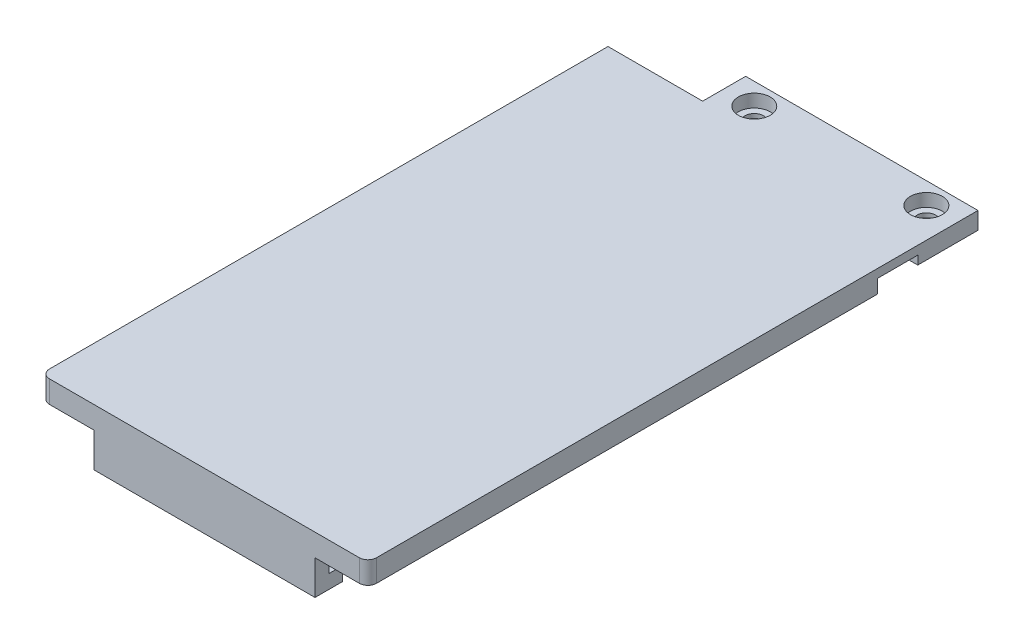
from build123d import *

# Parameters (mm, degrees)
SKETCH1_W                = 38
SKETCH1_H                = 65.9
BOSS_EXTRUDE1_DEPTH      = 1
BOSS_EXTRUDE2_DEPTH      = 1.58
SKETCH3_W                = 25.7
SKETCH3_H                = 1.6
BOSS_EXTRUDE3_DEPTH      = 4
SKETCH4_W                = 25.7
SKETCH4_H                = 1.6
BOSS_EXTRUDE4_DEPTH      = 1.6
FILLET1_R                = 1
SKETCH6_W                = 22
SKETCH6_H                = 7
BOSS_EXTRUDE5_DEPTH      = 1
BOSS_EXTRUDE5_DEPTH_BACK = 1
SKETCH9_W                = 5
SKETCH9_H                = 2
BOSS_EXTRUDE6_DEPTH      = 5
SKETCH7_R                = 1.075
CUT_EXTRUDE2_DEPTH       = 7.58
SKETCH8_R                = 1.85
CUT_EXTRUDE3_DEPTH       = 1.5


with BuildPart() as part:
    # Sketch1 → Boss-Extrude1 (new body)
    with BuildSketch(Plane(origin=(0, 0, 0), x_dir=(1, 0, 0), z_dir=(0, 1, 0))):
        Rectangle(SKETCH1_W, SKETCH1_H)
    extrude(amount=BOSS_EXTRUDE1_DEPTH)

    # Sketch2 → Boss-Extrude2 (add)
    with BuildSketch(Plane.XZ):
        Polygon((-19, 32.95), (-19, -26.25), (-17.4, -26.25), (-17.4, 31.35), (17.4, 31.35), (17.4, -26.25), (19, -26.25), (19, 32.95), align=None)
    extrude(amount=BOSS_EXTRUDE2_DEPTH)

    # Sketch3 → Boss-Extrude3 (add)
    with BuildSketch(Plane.XZ.offset(1.58)):
        with Locations((0, 32.15)):
            Rectangle(SKETCH3_W, SKETCH3_H)
    extrude(amount=BOSS_EXTRUDE3_DEPTH)

    # Sketch4 → Boss-Extrude4 (add)
    with BuildSketch(Plane(origin=(0, 0, 31.35), x_dir=(-1, 0, 0), z_dir=(0, 0, -1))):
        with Locations((0, -4.78)):
            Rectangle(SKETCH4_W, SKETCH4_H)
    extrude(amount=BOSS_EXTRUDE4_DEPTH)

    # Fillet1
    fillet1_edges = [part.edges().sort_by_distance(p)[0] for p in [
        (19, -0.29, 32.95),
        (-19, -0.29, 32.95),
    ]]
    fillet(fillet1_edges, radius=FILLET1_R)

    # Sketch6 → Boss-Extrude5 (add, two sides)
    with BuildSketch(Plane.XZ) as boss_extrude5_sk:
        with Locations((8, -34.45)):
            Rectangle(SKETCH6_W, SKETCH6_H)
    extrude(amount=BOSS_EXTRUDE5_DEPTH)
    extrude(boss_extrude5_sk.sketch, amount=-BOSS_EXTRUDE5_DEPTH_BACK)

    # Sketch9 → Boss-Extrude6 (add)
    with BuildSketch(Plane.ZY.offset(3)):
        with Locations((-35.45, 0)):
            Rectangle(SKETCH9_W, SKETCH9_H)
    extrude(amount=BOSS_EXTRUDE6_DEPTH)

    # Sketch7 → Cut-Extrude2 (cut, through all)
    with BuildSketch(Plane(origin=(0, 1, 0), x_dir=(1, 0, 0), z_dir=(0, 1, 0))):
        with Locations((-4.5, 35.45)):
            Circle(SKETCH7_R)
        with Locations((15.5, 35.45)):
            Circle(SKETCH7_R)
    extrude(amount=-CUT_EXTRUDE2_DEPTH, mode=Mode.SUBTRACT)

    # Sketch8 → Cut-Extrude3 (cut)
    with BuildSketch(Plane(origin=(0, 1, 0), x_dir=(1, 0, 0), z_dir=(0, 1, 0))):
        with Locations((-4.5, 35.45)):
            Circle(SKETCH8_R)
        with Locations((15.5, 35.45)):
            Circle(SKETCH8_R)
    extrude(amount=-CUT_EXTRUDE3_DEPTH, mode=Mode.SUBTRACT)


solid = part.part
